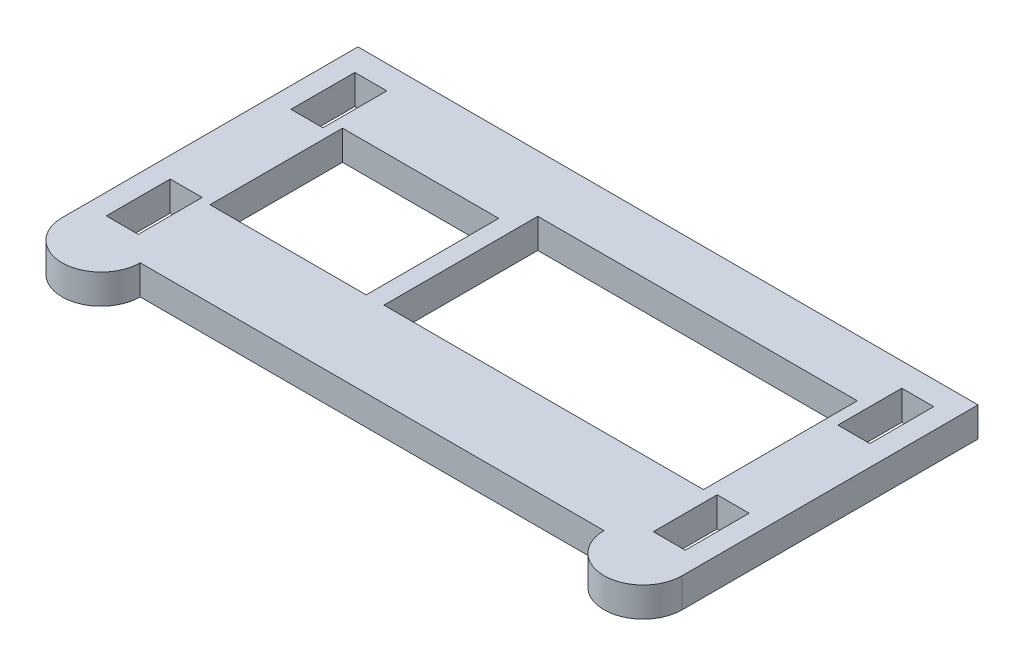
from build123d import *

# Parameters (mm, degrees)
SKETCH1_W           = 3.429
SKETCH1_H           = 6.858
SKETCH1_W_2         = 34.29
SKETCH1_H_2         = 16.51
SKETCH1_W_3         = 16.764
SKETCH1_H_3         = 14.224
BOSS_EXTRUDE1_DEPTH = 3.175


with BuildPart() as part:
    # Sketch1 → Boss-Extrude1 (new body)
    with BuildSketch(Plane(origin=(0, 0, 0), x_dir=(1, 0, 0), z_dir=(0, 1, 0))):
        with BuildLine():
            Line((-24.892, -15.875), (24.892, -15.875))
            ThreePointArc((24.892, -15.875), (29.083, -20.066), (33.274, -15.875))
            Line((33.274, -15.875), (33.274, 15.875))
            Line((33.274, 15.875), (-33.274, 15.875))
            Line((-33.274, 15.875), (-33.274, -15.875))
            ThreePointArc((-33.274, -15.875), (-29.083, -20.066), (-24.892, -15.875))
        make_face()
        with Locations((29.3497, 9.906)):
            Rectangle(SKETCH1_W, SKETCH1_H, mode=Mode.SUBTRACT)
        with Locations((29.3497, -9.906)):
            Rectangle(SKETCH1_W, SKETCH1_H, mode=Mode.SUBTRACT)
        with Locations((-29.3497, -9.906)):
            Rectangle(SKETCH1_W, SKETCH1_H, mode=Mode.SUBTRACT)
        with Locations((-29.3497, 9.906)):
            Rectangle(SKETCH1_W, SKETCH1_H, mode=Mode.SUBTRACT)
        with Locations((9.271, 1.524)):
            Rectangle(SKETCH1_W_2, SKETCH1_H_2, mode=Mode.SUBTRACT)
        with Locations((-18.161, 0.381)):
            Rectangle(SKETCH1_W_3, SKETCH1_H_3, mode=Mode.SUBTRACT)
    extrude(amount=BOSS_EXTRUDE1_DEPTH)


solid = part.part
